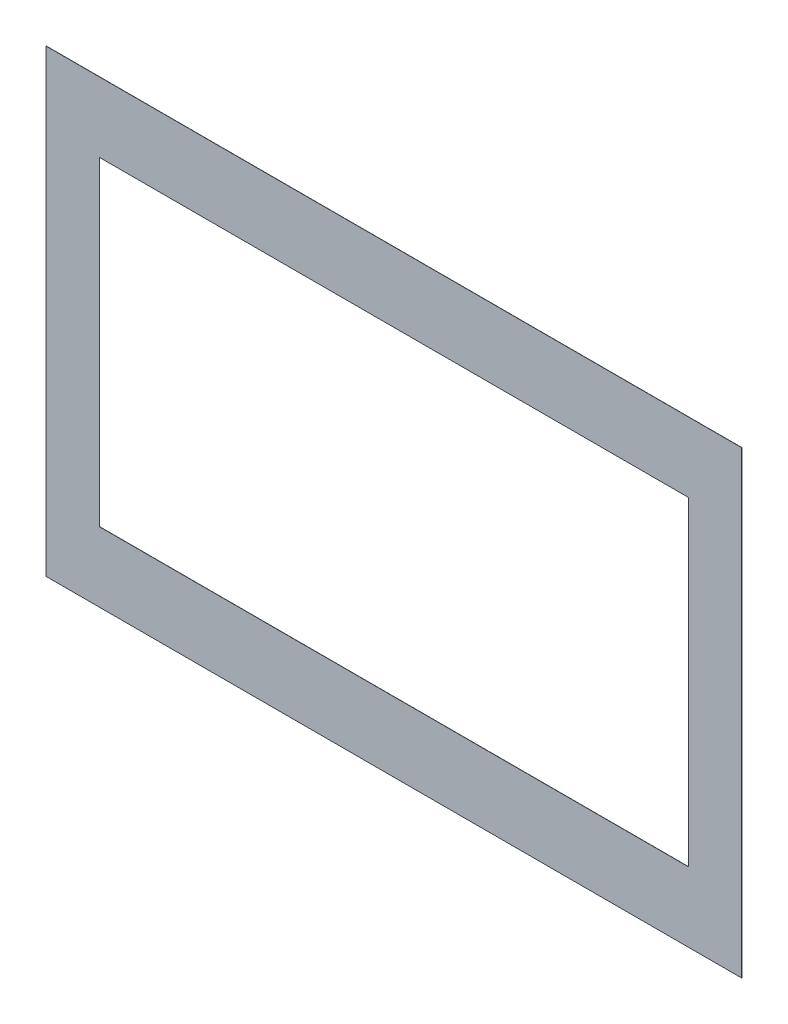
from build123d import *

# Parameters (mm, degrees)
SKETCH1_W               = 673.1
SKETCH1_H               = 444.5
BOSS_EXTRUDE1_DEPTH     = 0.1016
SKETCH2_W               = 569.9252
SKETCH2_H               = 309.5752
CUT_EXTRUDE1_DEPTH      = 1
CUT_EXTRUDE1_DEPTH_BACK = 1.2032


with BuildPart() as part:
    # Sketch1 → Boss-Extrude1 (new body, symmetric)
    with BuildSketch(Plane.XY):
        Rectangle(SKETCH1_W, SKETCH1_H)
    extrude(amount=BOSS_EXTRUDE1_DEPTH, both=True)

    # Sketch2 → Cut-Extrude1 (cut, two sides)
    with BuildSketch(Plane.XY.offset(0.1016)) as cut_extrude1_sk:
        Rectangle(SKETCH2_W, SKETCH2_H)
    extrude(amount=CUT_EXTRUDE1_DEPTH, mode=Mode.SUBTRACT)
    extrude(cut_extrude1_sk.sketch, amount=-CUT_EXTRUDE1_DEPTH_BACK, mode=Mode.SUBTRACT)


solid = part.part
